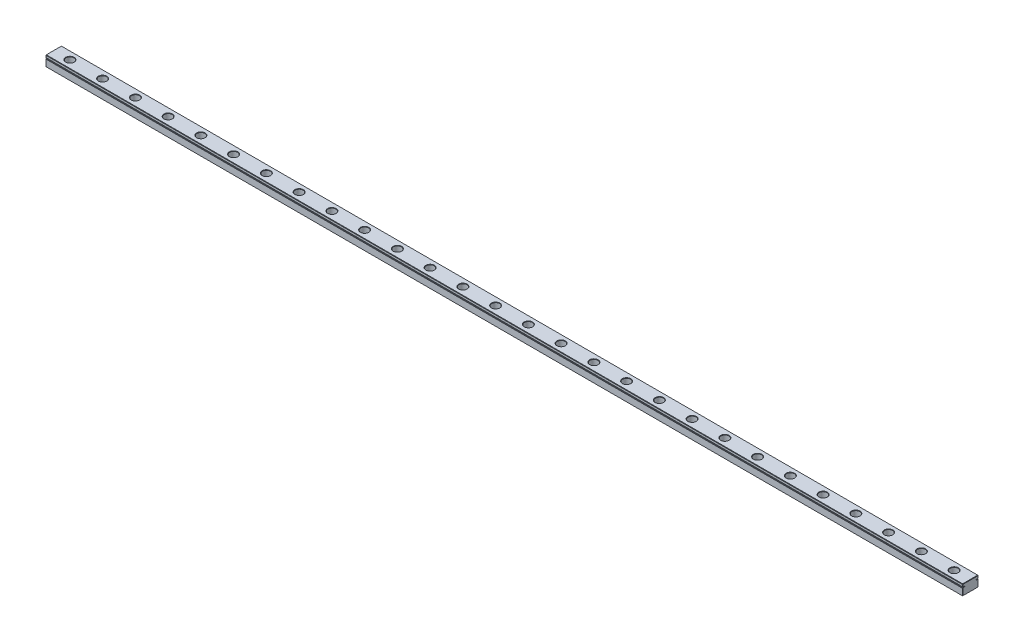
from build123d import *

# Parameters (mm, degrees)
SKETCH1_W            = 12
SKETCH1_H            = 8
BOSS_EXTRUDE1_DEPTH  = 700
CUT_EXTRUDE3_REACH   = 702.037
SKETCH4_W            = 1.75
SKETCH4_H            = 0.5
SKETCH5_R            = 1.75
CUT_EXTRUDE4_DEPTH   = 701.071424927
SKETCH5_3_R          = 3
SKETCH5_3_R_2        = 1.75
CUT_EXTRUDE5_DEPTH   = 4.5
LPATTERN1_COUNT      = 14
LPATTERN1_PITCH      = 25
LPATTERN1_COUNT_DIR2 = 15
LPATTERN1_PITCH_DIR2 = 25
CHAMFER1_SIZE        = 0.25


with BuildPart() as part:
    # Sketch1 → Boss-Extrude1 (new body)
    with BuildSketch(Plane(origin=(0, 0, 0), x_dir=(0, 0, -1), z_dir=(1, 0, 0))):
        Rectangle(SKETCH1_W, SKETCH1_H)
    extrude(amount=BOSS_EXTRUDE1_DEPTH)

    # Sketch4 → Cut-Extrude3 (cut, up to next)
    with BuildSketch(Plane.ZY, mode=Mode.PRIVATE) as cut_extrude3_sk1:
        with Locations((-5.125, 1.75)):
            Rectangle(SKETCH4_W, SKETCH4_H)
    cut_extrude3_tool1 = extrude(cut_extrude3_sk1.sketch, amount=-CUT_EXTRUDE3_REACH, mode=Mode.PRIVATE) & part.part
    # Sketch4 → Cut-Extrude3 (cut, up to next)
    with BuildSketch(Plane.ZY, mode=Mode.PRIVATE) as cut_extrude3_sk2:
        with Locations((5.125, 1.75)):
            Rectangle(SKETCH4_W, SKETCH4_H)
    cut_extrude3_tool2 = extrude(cut_extrude3_sk2.sketch, amount=-CUT_EXTRUDE3_REACH, mode=Mode.PRIVATE) & part.part
    add(cut_extrude3_tool1.solids().sort_by_distance((0, 1.75, -5.125))[0], mode=Mode.SUBTRACT)
    add(cut_extrude3_tool2.solids().sort_by_distance((0, 1.75, 5.125))[0], mode=Mode.SUBTRACT)

    # Sketch5 → Cut-Extrude4 (cut, through all)
    with BuildSketch(Plane(origin=(0, 4, 0), x_dir=(1, 0, 0), z_dir=(0, 1, 0))):
        with Locations((337.5, 0)):
            Circle(SKETCH5_R)
    cut_extrude4 = extrude(amount=-CUT_EXTRUDE4_DEPTH, mode=Mode.SUBTRACT)

    # Sketch5_3 → Cut-Extrude5 (cut)
    with BuildSketch(Plane(origin=(0, 4, 0), x_dir=(1, 0, 0), z_dir=(0, 1, 0))):
        with Locations((337.5, 0)):
            Circle(SKETCH5_3_R)
        with Locations((337.5, 0)):
            Circle(SKETCH5_3_R_2, mode=Mode.SUBTRACT)
    cut_extrude5 = extrude(amount=-CUT_EXTRUDE5_DEPTH, mode=Mode.SUBTRACT)

    # LPattern1: Cut-Extrude4, Cut-Extrude5 14 × 15
    with Locations(*[Vector(-1, 0, 0) * (i * LPATTERN1_PITCH) + Vector(1, 0, 0) * (j * LPATTERN1_PITCH_DIR2) for i in range(LPATTERN1_COUNT) for j in range(LPATTERN1_COUNT_DIR2) if (i, j) != (0, 0)]):
        add(cut_extrude4, mode=Mode.SUBTRACT)
        add(cut_extrude5, mode=Mode.SUBTRACT)

    # Chamfer1
    chamfer1_edges = [part.edges().sort_by_distance(p)[0] for p in [
        (335.75, -4, 0),
        (360.75, -4, 0),
        (385.75, -4, 0),
        (410.75, -4, 0),
        (435.75, -4, 0),
        (460.75, -4, 0),
        (485.75, -4, 0),
        (510.75, -4, 0),
        (535.75, -4, 0),
        (560.75, -4, 0),
        (585.75, -4, 0),
        (610.75, -4, 0),
        (635.75, -4, 0),
        (660.75, -4, 0),
        (685.75, -4, 0),
        (310.75, -4, 0),
        (285.75, -4, 0),
        (260.75, -4, 0),
        (235.75, -4, 0),
        (210.75, -4, 0),
        (185.75, -4, 0),
        (160.75, -4, 0),
        (135.75, -4, 0),
        (110.75, -4, 0),
        (85.75, -4, 0),
        (60.75, -4, 0),
        (35.75, -4, 0),
        (10.75, -4, 0),
        (700, -4, 0),
        (350, 2, -6),
        (700, 3, -6),
        (350, -4, -6),
        (700, -1.25, -6),
        (350, 1.5, -6),
        (700, 3, 6),
        (350, 2, 6),
        (350, -4, 6),
        (700, -1.25, 6),
        (350, 1.5, 6),
        (0, -4, 0),
        (0, -1.25, -6),
        (0, 1.5, -5.125),
        (0, 1.75, -4.25),
        (0, 2, -5.125),
        (0, 3, -6),
        (0, -1.25, 6),
        (0, 1.5, 5.125),
        (0, 1.75, 4.25),
        (0, 2, 5.125),
        (0, 3, 6),
        (350, 4, -6),
        (700, 4, 0),
        (350, 4, 6),
        (0, 4, 0),
        (334.5, 4, 0),
        (359.5, 4, 0),
        (384.5, 4, 0),
        (409.5, 4, 0),
        (434.5, 4, 0),
        (459.5, 4, 0),
        (484.5, 4, 0),
        (509.5, 4, 0),
        (534.5, 4, 0),
        (559.5, 4, 0),
        (584.5, 4, 0),
        (609.5, 4, 0),
        (634.5, 4, 0),
        (659.5, 4, 0),
        (684.5, 4, 0),
        (309.5, 4, 0),
        (284.5, 4, 0),
        (259.5, 4, 0),
        (234.5, 4, 0),
        (209.5, 4, 0),
        (184.5, 4, 0),
        (159.5, 4, 0),
        (134.5, 4, 0),
        (109.5, 4, 0),
        (84.5, 4, 0),
        (59.5, 4, 0),
        (34.5, 4, 0),
        (9.5, 4, 0),
    ]]
    chamfer(chamfer1_edges, length=CHAMFER1_SIZE)


solid = part.part
